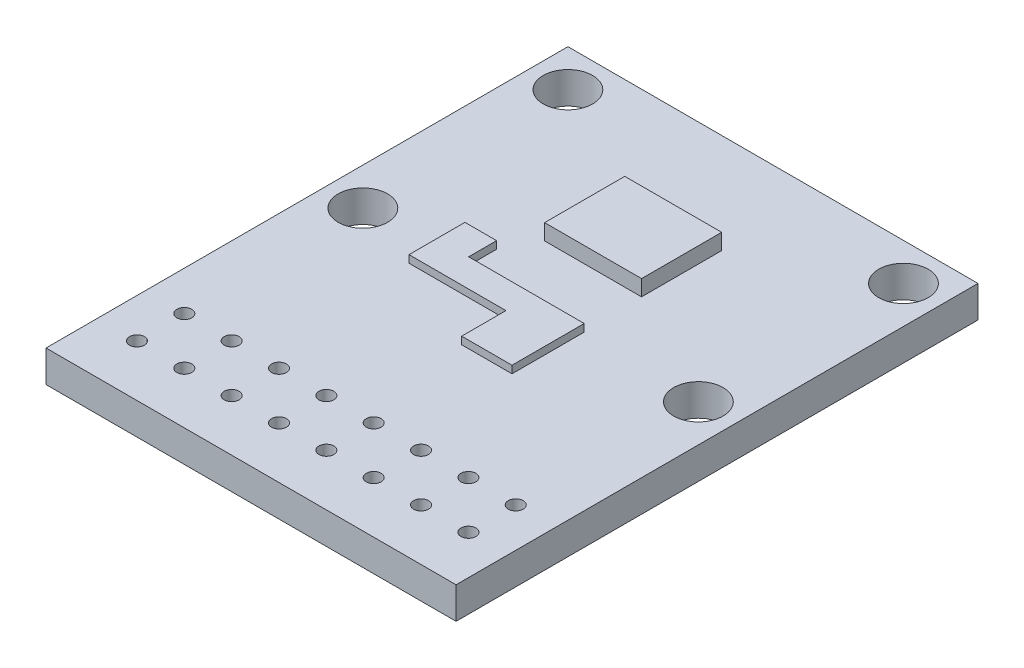
from build123d import *

# Parameters (mm, degrees)
BOSS_EXTRUDE1_DEPTH = 0.85
SKETCH2_R           = 1.325
SKETCH2_R_2         = 0.4
CUT_EXTRUDE1_DEPTH  = 24.326808612
SKETCH3_W           = 5.2
SKETCH3_H           = 4.3
BOSS_EXTRUDE2_DEPTH = 0.85
BOSS_EXTRUDE3_DEPTH = 0.4


with BuildPart() as part:
    # Sketch1 → Boss-Extrude1 (new, symmetric)
    with BuildSketch(Plane(origin=(0, 0, 0), x_dir=(1, 0, 0), z_dir=(0, 1, 0))):
        Polygon((-11, -7.5), (-11, -20.5), (11, -20.5), (11, -7.5), (11, 7.5), (-11, 7.5), align=None)
    extrude(amount=BOSS_EXTRUDE1_DEPTH, both=True)

    # Sketch2 → Cut-Extrude1 (cut, through all)
    with BuildSketch(Plane(origin=(0, 0.85, 0), x_dir=(1, 0, 0), z_dir=(0, 1, 0))):
        with Locations((-9, 5.5)):
            Circle(SKETCH2_R)
        with Locations((9, 5.5)):
            Circle(SKETCH2_R)
        with Locations((9, -5.5)):
            Circle(SKETCH2_R)
        with Locations((-9, -5.5)):
            Circle(SKETCH2_R)
        with Locations((-8.89, -15.19)):
            Circle(SKETCH2_R_2)
        with Locations((-6.35, -15.19)):
            Circle(SKETCH2_R_2)
        with Locations((-3.81, -15.19)):
            Circle(SKETCH2_R_2)
        with Locations((-1.27, -15.19)):
            Circle(SKETCH2_R_2)
        with Locations((1.27, -15.19)):
            Circle(SKETCH2_R_2)
        with Locations((3.81, -15.19)):
            Circle(SKETCH2_R_2)
        with Locations((6.35, -15.19)):
            Circle(SKETCH2_R_2)
        with Locations((8.89, -15.19)):
            Circle(SKETCH2_R_2)
        with Locations((-6.35, -17.73)):
            Circle(SKETCH2_R_2)
        with Locations((-3.81, -17.73)):
            Circle(SKETCH2_R_2)
        with Locations((-1.27, -17.73)):
            Circle(SKETCH2_R_2)
        with Locations((1.27, -17.73)):
            Circle(SKETCH2_R_2)
        with Locations((3.81, -17.73)):
            Circle(SKETCH2_R_2)
        with Locations((6.35, -17.73)):
            Circle(SKETCH2_R_2)
        with Locations((8.89, -17.73)):
            Circle(SKETCH2_R_2)
        with Locations((-8.89, -17.73)):
            Circle(SKETCH2_R_2)
    extrude(amount=-CUT_EXTRUDE1_DEPTH, mode=Mode.SUBTRACT)

    # Sketch3 → Boss-Extrude2 (add)
    with BuildSketch(Plane(origin=(0, 0.85, 0), x_dir=(1, 0, 0), z_dir=(0, 1, 0))):
        Rectangle(SKETCH3_W, SKETCH3_H)
    extrude(amount=BOSS_EXTRUDE2_DEPTH)

    # Sketch3_3 → Boss-Extrude3 (add)
    with BuildSketch(Plane(origin=(0, 0.85, 0), x_dir=(1, 0, 0), z_dir=(0, 1, 0))):
        Polygon((-5.2, -3.825), (-5.2, -6.825), (0, -6.825), (0, -9.2), (2.7, -9.2), (2.7, -5.325), (-3.5, -5.325), (-3.5, -3.825), align=None)
    extrude(amount=BOSS_EXTRUDE3_DEPTH)


solid = part.part
